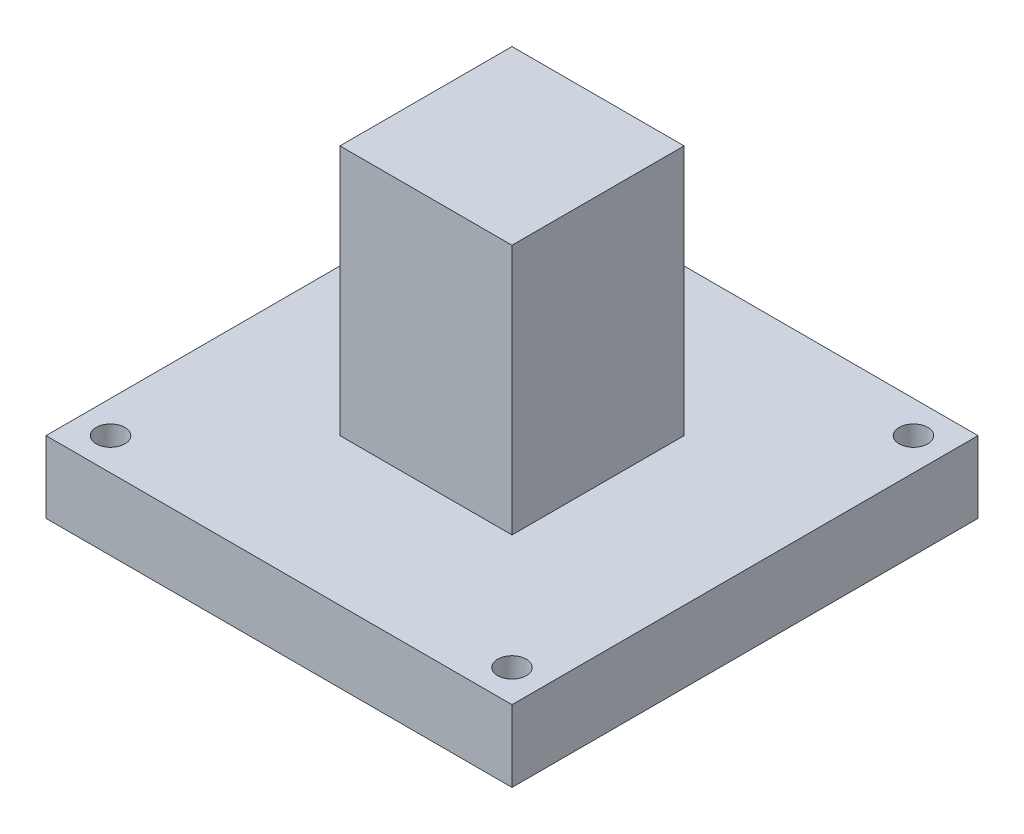
from build123d import *

# Parameters (mm, degrees)
SKETCH1_W           = 24
SKETCH1_H           = 24
BOSS_EXTRUDE1_DEPTH = 35
SKETCH2_W           = 65
SKETCH2_H           = 65
SKETCH2_R           = 2
BOSS_EXTRUDE2_DEPTH = 10
SKETCH3_R           = 2.5
CUT_EXTRUDE1_DEPTH  = 7


with BuildPart() as part:
    # Sketch1 → Boss-Extrude1 (new body)
    with BuildSketch(Plane(origin=(0, 0, 0), x_dir=(1, 0, 0), z_dir=(0, 1, 0))):
        with Locations((12, 12)):
            Rectangle(SKETCH1_W, SKETCH1_H)
    extrude(amount=BOSS_EXTRUDE1_DEPTH)

    # Sketch2 → Boss-Extrude2 (add)
    with BuildSketch(Plane.XZ):
        with Locations((12, -12)):
            Rectangle(SKETCH2_W, SKETCH2_H)
        with Locations((-16, 16)):
            Circle(SKETCH2_R, mode=Mode.SUBTRACT)
        with Locations((-16, -40)):
            Circle(SKETCH2_R, mode=Mode.SUBTRACT)
        with Locations((40, 16)):
            Circle(SKETCH2_R, mode=Mode.SUBTRACT)
        with Locations((40, -40)):
            Circle(SKETCH2_R, mode=Mode.SUBTRACT)
    extrude(amount=BOSS_EXTRUDE2_DEPTH)

    # Sketch3 → Cut-Extrude1 (cut)
    with BuildSketch(Plane.XZ.offset(10)):
        with Locations((12, 16)):
            Circle(SKETCH3_R)
        with Locations((12, -40)):
            Circle(SKETCH3_R)
    extrude(amount=-CUT_EXTRUDE1_DEPTH, mode=Mode.SUBTRACT)


solid = part.part
